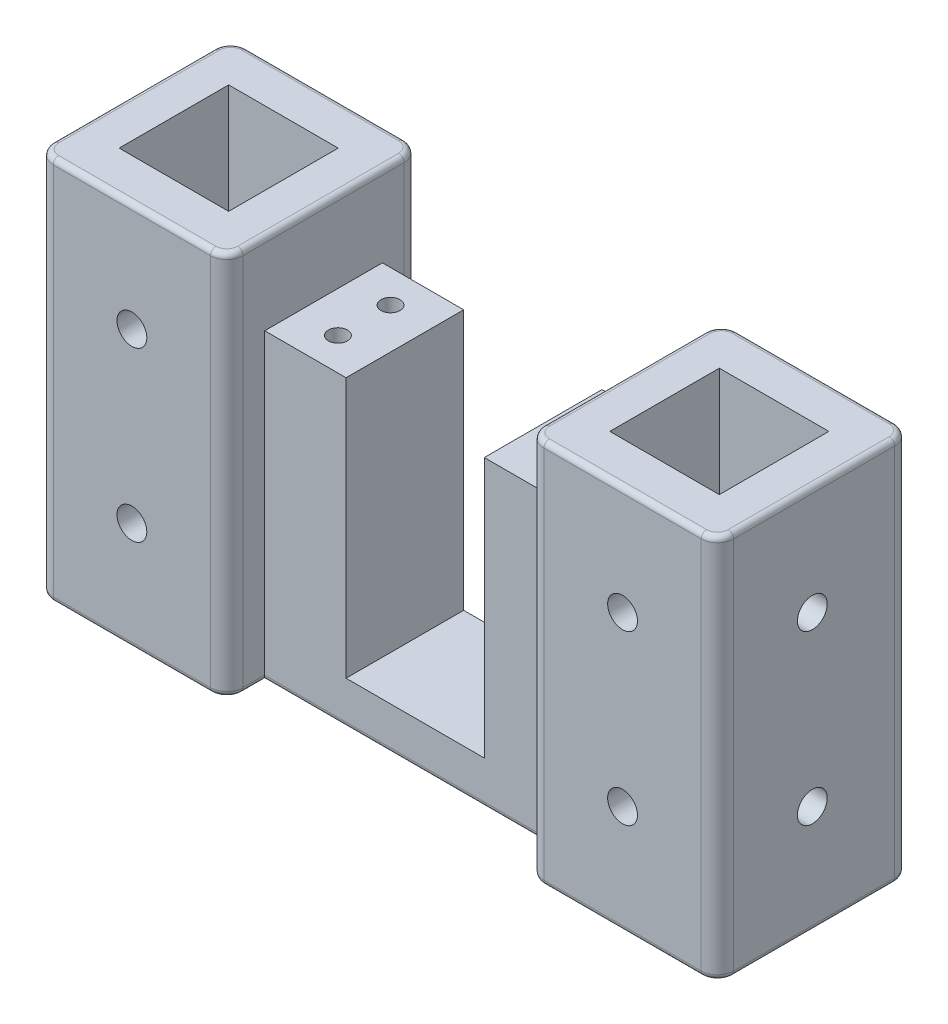
from build123d import *

# Parameters (mm, degrees)
BOSS_EXTRUDE1_DEPTH     = 21.7
SKETCH2_R               = 1.75
CUT_EXTRUDE1_DEPTH      = 10
SKETCH3_W               = 35.7
SKETCH3_H               = 71
BOSS_EXTRUDE2_DEPTH     = 35
SKETCH4_W               = 20.2
SKETCH4_H               = 20.2
CUT_EXTRUDE2_DEPTH      = 72
SKETCH5_R               = 2.75
CUT_EXTRUDE3_DEPTH      = 10
MIRROR5_COPY_1_SKETCH_R = 2.75
MIRROR5_COPY_1_DEPTH    = 10
MIRROR5_COPY_2_SKETCH_R = 2.75
MIRROR5_COPY_2_DEPTH    = 10
MIRROR6_COPY_1_SKETCH_R = 2.75
MIRROR6_COPY_1_DEPTH    = 10
FILLET1_R               = 3
FILLET2_R               = 1


with BuildPart() as part:
    # Sketch1 → Boss-Extrude1 (new body)
    with BuildSketch(Plane.XY):
        Polygon((27.75, 0), (-27.75, 0), (-27.75, 56), (-12.75, 56), (-12.75, 8), (12.75, 8), (12.75, 56), (27.75, 56), align=None)
    extrude(amount=BOSS_EXTRUDE1_DEPTH)

    # Sketch2 → Cut-Extrude1 (cut)
    with BuildSketch(Plane(origin=(0, 56, 0), x_dir=(1, 0, 0), z_dir=(0, 1, 0))):
        with Locations((20.25, -6)):
            Circle(SKETCH2_R)
        with Locations((20.25, -15.7)):
            Circle(SKETCH2_R)
        with Locations((-20.25, -15.7)):
            Circle(SKETCH2_R)
        with Locations((-20.25, -6)):
            Circle(SKETCH2_R)
    extrude(amount=-CUT_EXTRUDE1_DEPTH, mode=Mode.SUBTRACT)

    # Sketch3 → Boss-Extrude2 (add)
    with BuildSketch(Plane(origin=(27.75, 0, 0), x_dir=(0, 0, -1), z_dir=(1, 0, 0))):
        with Locations((-10.85, 35.5)):
            Rectangle(SKETCH3_W, SKETCH3_H)
    boss_extrude2 = extrude(amount=BOSS_EXTRUDE2_DEPTH)

    # Mirror1: Boss-Extrude2 across plane
    add(boss_extrude2.mirror(Plane(origin=(0, 0, 0), x_dir=(0, 0, 1), z_dir=(1, 0, 0))))

    # Sketch4 → Cut-Extrude2 (cut, through all)
    with BuildSketch(Plane.XZ):
        with Locations((45.25, 10.85)):
            Rectangle(SKETCH4_W, SKETCH4_H)
    cut_extrude2 = extrude(amount=-CUT_EXTRUDE2_DEPTH, mode=Mode.SUBTRACT)

    # Mirror2: Cut-Extrude2 across plane
    add(cut_extrude2.mirror(Plane(origin=(0, 0, 0), x_dir=(0, 0, 1), z_dir=(1, 0, 0))), mode=Mode.SUBTRACT)

    # Sketch5 → Cut-Extrude3 (cut)
    with BuildSketch(Plane.XY.offset(28.7)):
        with Locations((45.25, 51)):
            Circle(SKETCH5_R)
        with Locations((45.25, 20)):
            Circle(SKETCH5_R)
    cut_extrude3 = extrude(amount=-CUT_EXTRUDE3_DEPTH, mode=Mode.SUBTRACT)

    # Mirror3: Cut-Extrude3 across plane
    add(cut_extrude3.mirror(Plane(origin=(0, 0, 0), x_dir=(0, 0, 1), z_dir=(1, 0, 0))), mode=Mode.SUBTRACT)

    # Mirror4: Cut-Extrude3 across plane
    add(cut_extrude3.mirror(Plane(origin=(17.649039404, 0, -17.302979808), x_dir=(0.700071411, 0, 0.714072839), z_dir=(0.714072839, 0, -0.700071411))), mode=Mode.SUBTRACT)

    # Mirror5 copy 1 sketch → Mirror5 copy 1 (cut)
    with BuildSketch(Plane(origin=(-63.99245246, 0, -34.03769849), x_dir=(0.019800039, 0, 0.99980396), z_dir=(-0.99980396, 0, 0.019800039))):
        with Locations((45.25, 51)):
            Circle(MIRROR5_COPY_1_SKETCH_R)
        with Locations((45.25, 20)):
            Circle(MIRROR5_COPY_1_SKETCH_R)
    extrude(amount=-MIRROR5_COPY_1_DEPTH, mode=Mode.SUBTRACT)

    # Mirror5 copy 2 sketch → Mirror5 copy 2 (cut)
    with BuildSketch(Plane(origin=(-63.99245246, 0, -34.03769849), x_dir=(-0.019800039, 0, -0.99980396), z_dir=(-0.99980396, 0, 0.019800039))):
        with Locations((45.25, -51)):
            Circle(MIRROR5_COPY_2_SKETCH_R)
        with Locations((45.25, -20)):
            Circle(MIRROR5_COPY_2_SKETCH_R)
    extrude(amount=-MIRROR5_COPY_2_DEPTH, mode=Mode.SUBTRACT)

    # Mirror6: Cut-Extrude3 across plane
    add(cut_extrude3.mirror(Plane(origin=(0, 0, 10.85), x_dir=(1, 0, 0), z_dir=(0, 0, -1))), mode=Mode.SUBTRACT)

    # Mirror6 copy 1 sketch → Mirror6 copy 1 (cut)
    with BuildSketch(Plane(origin=(0, 0, -7), x_dir=(-1, 0, 0), z_dir=(0, 0, -1))):
        with Locations((45.25, 51)):
            Circle(MIRROR6_COPY_1_SKETCH_R)
        with Locations((45.25, 20)):
            Circle(MIRROR6_COPY_1_SKETCH_R)
    extrude(amount=-MIRROR6_COPY_1_DEPTH, mode=Mode.SUBTRACT)

    # Fillet1
    fillet1_edges = [part.edges().sort_by_distance(p)[0] for p in [
        (27.75, 35.5, -7),
        (27.75, 35.5, 28.7),
        (62.75, 35.5, -7),
        (62.75, 35.5, 28.7),
        (-27.75, 35.5, -7),
        (-27.75, 35.5, 28.7),
        (-62.75, 35.5, -7),
        (-62.75, 35.5, 28.7),
    ]]
    fillet(fillet1_edges, radius=FILLET1_R)

    # Fillet2
    fillet2_edges = [part.edges().sort_by_distance(p)[0] for p in [
        (-45.25, 71, 28.7),
        (-45.25, 0, 28.7),
        (45.25, 0, -7),
        (62.75, 0, 10.85),
        (45.25, 0, 28.7),
        (27.75, 0, 23.7),
        (-27.75, 0, 23.7),
        (-62.75, 0, 10.85),
        (-45.25, 0, -7),
        (-61.871320344, 0, -6.121320344),
        (-28.628679656, 0, -6.121320344),
        (28.628679656, 0, -6.121320344),
        (61.871320344, 0, -6.121320344),
        (61.871320344, 0, 27.821320344),
        (28.628679656, 0, 27.821320344),
        (-28.628679656, 0, 27.821320344),
        (-61.871320344, 0, 27.821320344),
        (-62.75, 71, 10.85),
        (-27.75, 71, 10.85),
        (-45.25, 71, -7),
        (-61.871320344, 71, -6.121320344),
        (-28.628679656, 71, -6.121320344),
        (-28.628679656, 71, 27.821320344),
        (-61.871320344, 71, 27.821320344),
        (45.25, 71, 28.7),
        (27.75, 71, 10.85),
        (62.75, 71, 10.85),
        (45.25, 71, -7),
        (28.628679656, 71, -6.121320344),
        (61.871320344, 71, -6.121320344),
        (61.871320344, 71, 27.821320344),
        (28.628679656, 71, 27.821320344),
        (0, 0, 21.7),
        (27.75, 0, -2),
        (-27.75, 0, -2),
        (0, 0, 0),
    ]]
    fillet(fillet2_edges, radius=FILLET2_R)


solid = part.part
